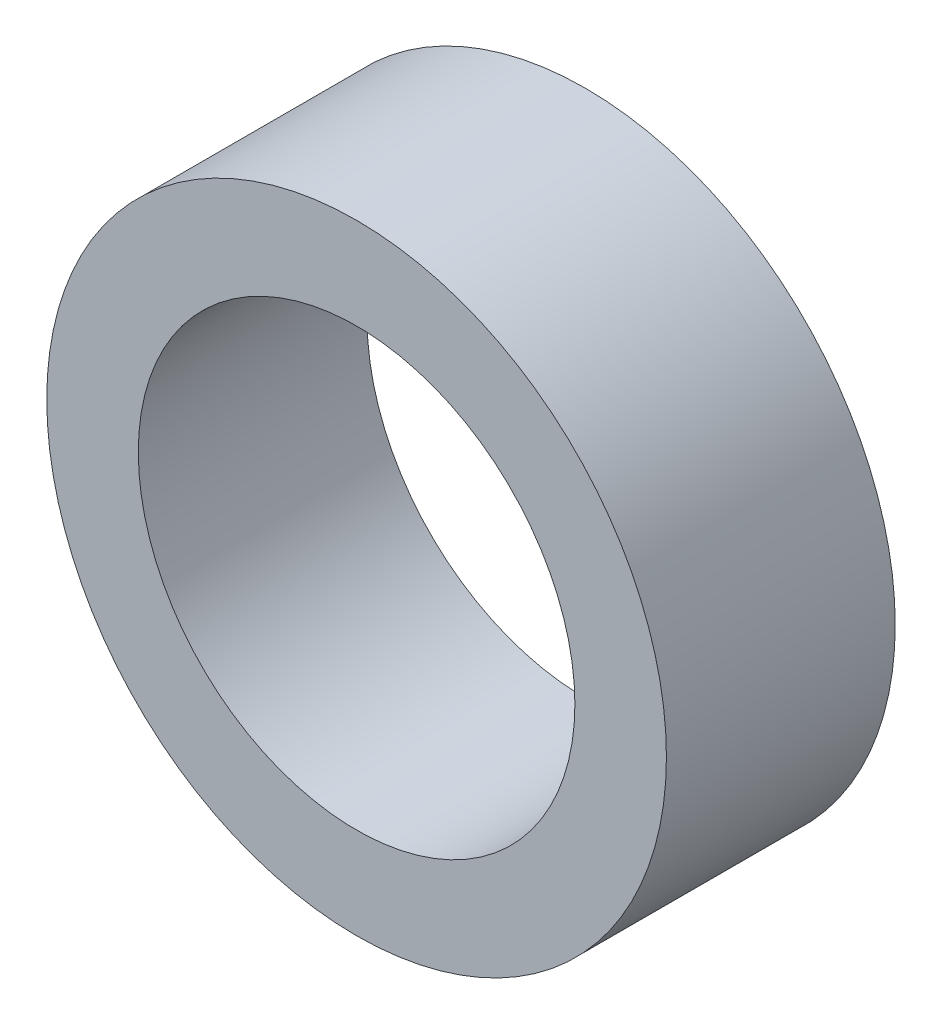
from build123d import *

# Parameters (mm, degrees)
SKETCH1_R           = 8.598499948
SKETCH1_R_2         = 6.058499948
BOSS_EXTRUDE1_DEPTH = 6.35


with BuildPart() as part:
    # Sketch1 → Boss-Extrude1 (new body)
    with BuildSketch(Plane.XY):
        Circle(SKETCH1_R)
        Circle(SKETCH1_R_2, mode=Mode.SUBTRACT)
    extrude(amount=BOSS_EXTRUDE1_DEPTH)


solid = part.part
